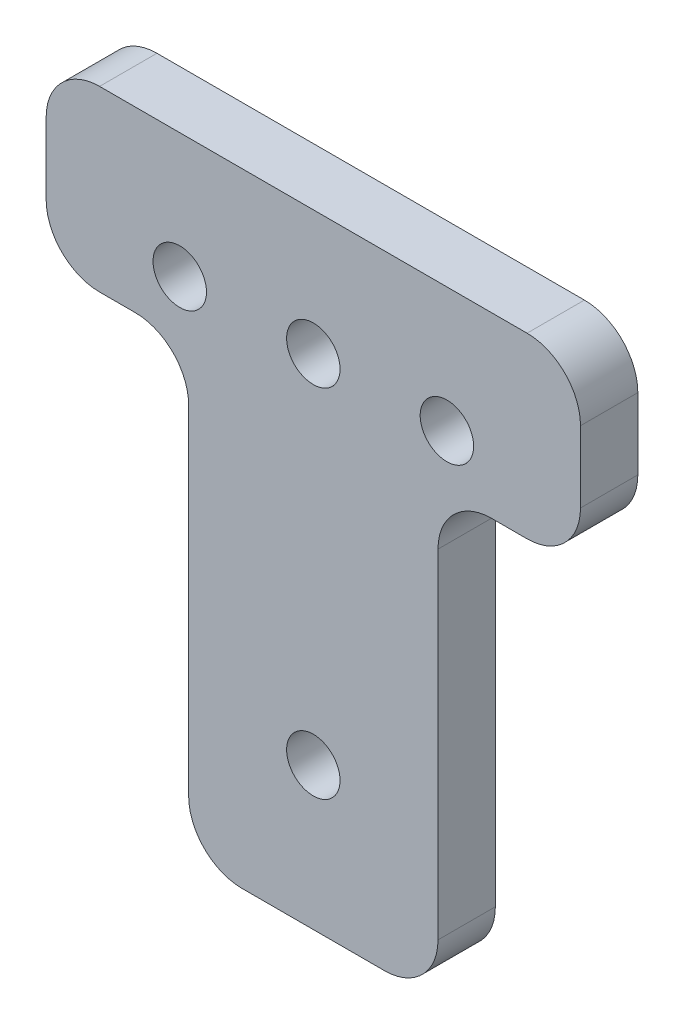
from build123d import *

# Parameters (mm, degrees)
SKETCH1_R           = 1.5
BOSS_EXTRUDE1_DEPTH = 1.61
FILLET1_R           = 3


with BuildPart() as part:
    # Sketch1 → Boss-Extrude1 (new body, symmetric)
    with BuildSketch(Plane.XY):
        Polygon((-7, 12.5), (-15, 12.5), (-15, 22.5), (15, 22.5), (15, 12.5), (7, 12.5), (7, -12.5), (-7, -12.5), align=None)
        with Locations((-7.5, 15.5)):
            Circle(SKETCH1_R, mode=Mode.SUBTRACT)
        with Locations((0, 15.5)):
            Circle(SKETCH1_R, mode=Mode.SUBTRACT)
        with Locations((7.5, 15.5)):
            Circle(SKETCH1_R, mode=Mode.SUBTRACT)
        with Locations((0, -4.5)):
            Circle(SKETCH1_R, mode=Mode.SUBTRACT)
    extrude(amount=BOSS_EXTRUDE1_DEPTH, both=True)

    # Fillet1
    fillet1_edges = [part.edges().sort_by_distance(p)[0] for p in [
        (7, 12.5, 0),
        (7, -12.5, 0),
        (-7, -12.5, 0),
        (-7, 12.5, 0),
        (-15, 12.5, 0),
        (-15, 22.5, 0),
        (15, 22.5, 0),
        (15, 12.5, 0),
    ]]
    fillet(fillet1_edges, radius=FILLET1_R)


solid = part.part
